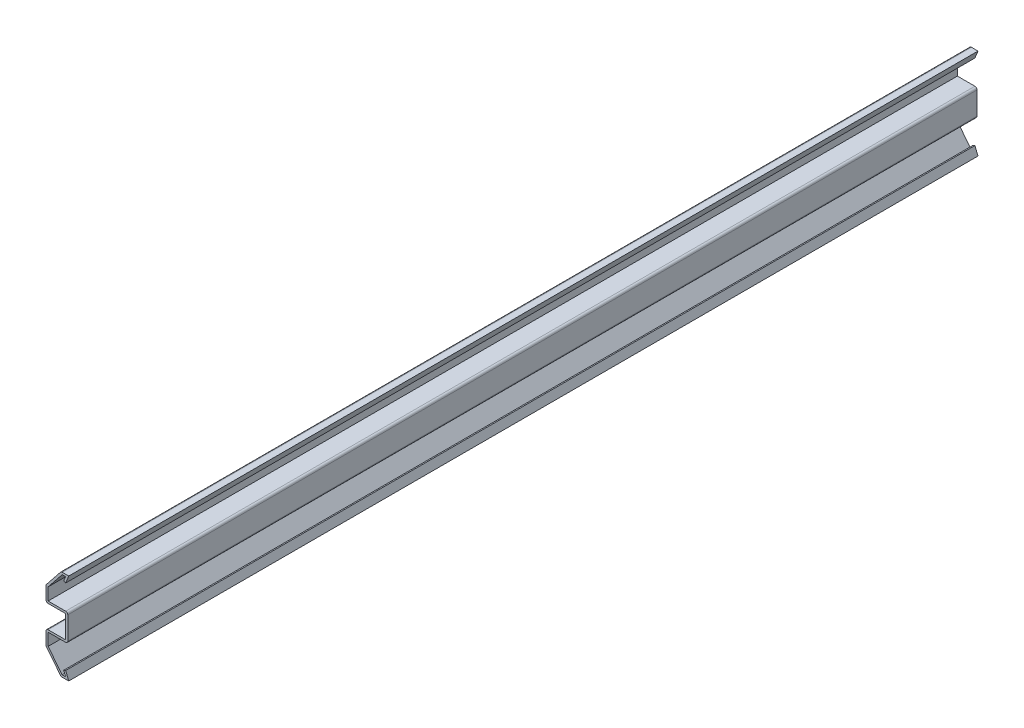
from build123d import *

# Parameters (mm, degrees)
EXTRUDE_THIN1_DEPTH = 381
FILLET1_R           = 0.889


with BuildPart() as part:
    # Sketch1 → Extrude-Thin1 (new body)
    with BuildSketch(Plane.XY):
        Polygon((-1.285875, 3.175), (0, 0), (-3.175, 0), (-9.525, 7.9375), (-9.525, 14.2875), (-1.285875, 14.2875), (-1.285875, 23.8125), (-9.525, 23.8125), (-9.525, 30.1625), (-3.175, 38.1), (0, 38.1), (-1.285875, 34.925), (-2.109862469, 35.258714925), (-1.319187013, 37.211), (-2.747724511, 37.211), (-8.636, 29.850655638), (-8.636, 24.7015), (-0.396875, 24.7015), (-0.396875, 13.3985), (-8.636, 13.3985), (-8.636, 8.249344362), (-2.747724511, 0.889), (-1.319187013, 0.889), (-2.109862469, 2.841285075), align=None)
    extrude(amount=-EXTRUDE_THIN1_DEPTH)

    # Fillet1
    fillet1_edges = [part.edges().sort_by_distance(p)[0] for p in [
        (-3.175, 0, -190.5),
        (-9.525, 7.9375, -190.5),
        (-9.525, 14.2875, -190.5),
        (-9.525, 23.8125, -190.5),
        (-9.525, 30.1625, -190.5),
        (-3.175, 38.1, -190.5),
        (-0.396875, 24.7015, -190.5),
        (-0.396875, 13.3985, -190.5),
    ]]
    fillet(fillet1_edges, radius=FILLET1_R)


solid = part.part
